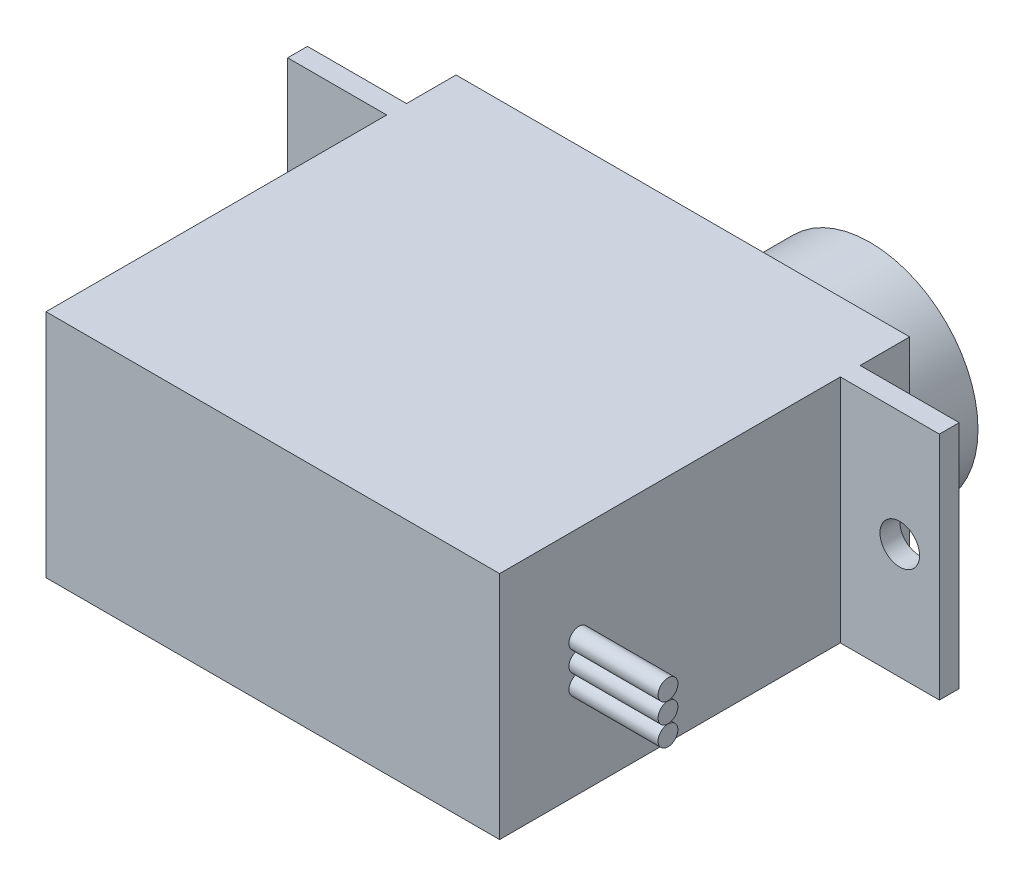
from build123d import *

# Parameters (mm, degrees)
SKETCH1_W            = 22.9
SKETCH1_H            = 20.7
BOSS_EXTRUDE1_DEPTH  = 11.63
SKETCH3_R            = 5.45
BOSS_EXTRUDE2_DEPTH  = 3.5
SKETCH4_W            = 1
SKETCH4_H            = 11.63
BOSS_EXTRUDE3_DEPTH  = 5
SKETCH5_R            = 1
CUT_EXTRUDE1_DEPTH   = 1
BOSS_EXTRUDE4_DEPTH  = 2.2
SKETCH8_R            = 0.5
BOSS_EXTRUDE6_DEPTH  = 4.5
SKETCH10_R           = 0.5
BOSS_EXTRUDE9_DEPTH  = 4.5
SKETCH9_R            = 0.5
BOSS_EXTRUDE10_DEPTH = 4.5
SKETCH13_R           = 0.5
CUT_EXTRUDE2_DEPTH   = 2.2


with BuildPart() as part:
    # Sketch1 → Boss-Extrude1 (new body)
    with BuildSketch(Plane(origin=(0, 0, 0), x_dir=(1, 0, 0), z_dir=(0, 1, 0))):
        with Locations((11.45, 10.35)):
            Rectangle(SKETCH1_W, SKETCH1_H)
    extrude(amount=BOSS_EXTRUDE1_DEPTH)

    # Sketch3 → Boss-Extrude2 (add)
    with BuildSketch(Plane(origin=(0, 0, -20.7), x_dir=(-1, 0, 0), z_dir=(0, 0, -1))):
        with Locations((-17.4, 5.815)):
            Circle(SKETCH3_R)
    extrude(amount=BOSS_EXTRUDE2_DEPTH)

    # Sketch4 → Boss-Extrude3 (add)
    with BuildSketch(Plane(origin=(22.9, 0, 0), x_dir=(0, 0, -1), z_dir=(1, 0, 0))):
        with Locations((17.7, 5.815)):
            Rectangle(SKETCH4_W, SKETCH4_H)
    boss_extrude3 = extrude(amount=BOSS_EXTRUDE3_DEPTH)

    # Sketch5 → Cut-Extrude1 (cut)
    with BuildSketch(Plane(origin=(0, 0, -18.2), x_dir=(-1, 0, 0), z_dir=(0, 0, -1))):
        with Locations((-25.9, 5.815)):
            Circle(SKETCH5_R)
    cut_extrude1 = extrude(amount=-CUT_EXTRUDE1_DEPTH, mode=Mode.SUBTRACT)

    # Mirror1: Boss-Extrude3, Cut-Extrude1 across plane
    add(boss_extrude3.mirror(Plane.ZY.offset(-11.45)))
    add(cut_extrude1.mirror(Plane.ZY.offset(-11.45)), mode=Mode.SUBTRACT)

    # Sketch6 → Boss-Extrude4 (add)
    with BuildSketch(Plane(origin=(0, 0, -24.2), x_dir=(-1, 0, 0), z_dir=(0, 0, -1))):
        Polygon((-17.4, 7.815), (-17.728528158, 7.466622583), (-18.165366865, 7.662759065), (-18.33556904, 7.215178017), (-18.814213562, 7.229213562), (-18.800178017, 6.75056904), (-19.247759065, 6.580366865), (-19.051622583, 6.143528158), (-19.4, 5.815), (-19.051622583, 5.486471842), (-19.247759065, 5.049633135), (-18.800178017, 4.87943096), (-18.814213562, 4.400786438), (-18.33556904, 4.414821983), (-18.165366865, 3.967240935), (-17.728528158, 4.163377417), (-17.4, 3.815), (-17.071471842, 4.163377417), (-16.634633135, 3.967240935), (-16.46443096, 4.414821983), (-15.985786438, 4.400786438), (-15.999821983, 4.87943096), (-15.552240935, 5.049633135), (-15.748377417, 5.486471842), (-15.4, 5.815), (-15.748377417, 6.143528158), (-15.552240935, 6.580366865), (-15.999821983, 6.75056904), (-15.985786438, 7.229213562), (-16.46443096, 7.215178017), (-16.634633135, 7.662759065), (-17.071471842, 7.466622583), align=None)
    extrude(amount=BOSS_EXTRUDE4_DEPTH)

    # Sketch8 → Boss-Extrude6 (add)
    with BuildSketch(Plane(origin=(22.9, 0, 0), x_dir=(0, 0, -1), z_dir=(1, 0, 0))):
        with Locations((4, 5.815)):
            Circle(SKETCH8_R)
    extrude(amount=BOSS_EXTRUDE6_DEPTH)

    # Sketch10 → Boss-Extrude9 (add)
    with BuildSketch(Plane(origin=(22.9, 0, 0), x_dir=(0, 0, -1), z_dir=(1, 0, 0))):
        with Locations((4, 4.805)):
            Circle(SKETCH10_R)
    extrude(amount=BOSS_EXTRUDE9_DEPTH)

    # Sketch9 → Boss-Extrude10 (add)
    with BuildSketch(Plane(origin=(22.9, 0, 0), x_dir=(0, 0, -1), z_dir=(1, 0, 0))):
        with Locations((4, 6.825)):
            Circle(SKETCH9_R)
    extrude(amount=BOSS_EXTRUDE10_DEPTH)

    # Sketch13 → Cut-Extrude2 (cut)
    with BuildSketch(Plane(origin=(0, 0, -26.4), x_dir=(-1, 0, 0), z_dir=(0, 0, -1))):
        with Locations((-17.4, 5.815)):
            Circle(SKETCH13_R)
    extrude(amount=-CUT_EXTRUDE2_DEPTH, mode=Mode.SUBTRACT)


solid = part.part
